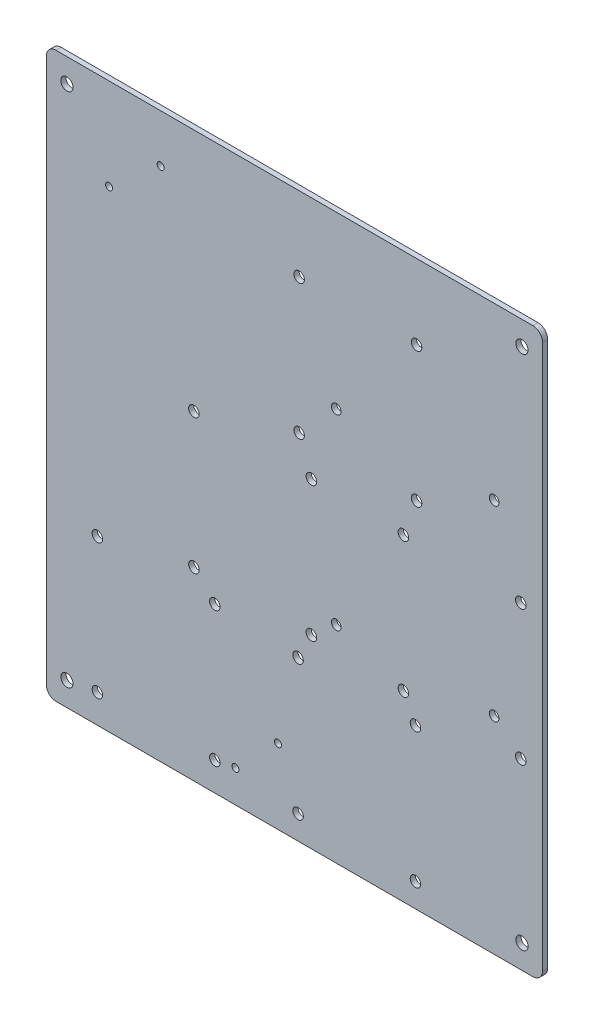
from build123d import *

# Parameters (mm, degrees)
SKETCH1_W           = 154
SKETCH1_H           = 175
BOSS_EXTRUDE1_DEPTH = 1.6
FILLET1_R           = 3
SKETCH2_R           = 1.89865
CUT_EXTRUDE1_DEPTH  = 2.6
SKETCH3_R           = 1.63195
CUT_EXTRUDE2_DEPTH  = 2.6
SKETCH4_R           = 1.5
CUT_EXTRUDE3_DEPTH  = 2.6
SKETCH5_R           = 1.09
CUT_EXTRUDE4_DEPTH  = 2.6


with BuildPart() as part:
    # Sketch1 → Boss-Extrude1 (new body)
    with BuildSketch(Plane.XY):
        Rectangle(SKETCH1_W, SKETCH1_H)
    extrude(amount=BOSS_EXTRUDE1_DEPTH)

    # Fillet1
    fillet1_edges = [part.edges().sort_by_distance(p)[0] for p in [
        (77, -87.5, 0.8),
        (-77, -87.5, 0.8),
        (-77, 87.5, 0.8),
        (77, 87.5, 0.8),
    ]]
    fillet(fillet1_edges, radius=FILLET1_R)

    # Sketch2 → Cut-Extrude1 (cut, through all)
    with BuildSketch(Plane.XY.offset(1.6)):
        with Locations((-70.612, 80.137)):
            Circle(SKETCH2_R)
        with Locations((70.612, 80.137)):
            Circle(SKETCH2_R)
        with Locations((70.612, -80.137)):
            Circle(SKETCH2_R)
        with Locations((-70.612, -80.137)):
            Circle(SKETCH2_R)
    extrude(amount=-CUT_EXTRUDE1_DEPTH, mode=Mode.SUBTRACT)

    # Sketch3 → Cut-Extrude2 (cut, through all)
    with BuildSketch(Plane.XY.offset(1.6)):
        with Locations((1.460377772, 64.310456987)):
            Circle(SKETCH3_R)
        with Locations((37.909377772, 64.310456987)):
            Circle(SKETCH3_R)
        with Locations((37.909377772, 22.400456987)):
            Circle(SKETCH3_R)
        with Locations((1.460377772, 22.400456987)):
            Circle(SKETCH3_R)
        with Locations((33.813625676, 11.150933339)):
            Circle(SKETCH3_R)
        with Locations((70.262625674, 11.150933339)):
            Circle(SKETCH3_R)
        with Locations((70.262625674, -30.759066661)):
            Circle(SKETCH3_R)
        with Locations((33.813625676, -30.759066661)):
            Circle(SKETCH3_R)
        with Locations((1.126771482, -38.187714501)):
            Circle(SKETCH3_R)
        with Locations((37.575771481, -38.187714501)):
            Circle(SKETCH3_R)
        with Locations((37.575771481, -80.097714501)):
            Circle(SKETCH3_R)
        with Locations((1.126771482, -80.097714501)):
            Circle(SKETCH3_R)
        with Locations((-31.190042853, 11.891013056)):
            Circle(SKETCH3_R)
        with Locations((5.258957145, 11.891013056)):
            Circle(SKETCH3_R)
        with Locations((5.258957145, -30.018986944)):
            Circle(SKETCH3_R)
        with Locations((-31.190042853, -30.018986944)):
            Circle(SKETCH3_R)
        with Locations((-61.163271416, -36.707555066)):
            Circle(SKETCH3_R)
        with Locations((-24.714271417, -36.707555066)):
            Circle(SKETCH3_R)
        with Locations((-24.714271417, -78.617555066)):
            Circle(SKETCH3_R)
        with Locations((-61.163271416, -78.617555066)):
            Circle(SKETCH3_R)
    extrude(amount=-CUT_EXTRUDE2_DEPTH, mode=Mode.SUBTRACT)

    # Sketch4 → Cut-Extrude3 (cut, through all)
    with BuildSketch(Plane.XY.offset(1.6)):
        with Locations((12.986023067, 34.581675178)):
            Circle(SKETCH4_R)
        with Locations((61.986023067, 34.581675178)):
            Circle(SKETCH4_R)
        with Locations((61.986023067, -23.418324822)):
            Circle(SKETCH4_R)
        with Locations((12.986023067, -23.418324822)):
            Circle(SKETCH4_R)
    extrude(amount=-CUT_EXTRUDE3_DEPTH, mode=Mode.SUBTRACT)

    # Sketch5 → Cut-Extrude4 (cut, through all)
    with BuildSketch(Plane(origin=(0, 0, 0), x_dir=(-1, 0, 0), z_dir=(0, 0, -1))):
        with Locations((41.518941969, 72.631735316)):
            Circle(SKETCH5_R)
        with Locations((57.518941969, 59.131735316)):
            Circle(SKETCH5_R)
        with Locations((18.301790213, -77.528250676)):
            Circle(SKETCH5_R)
        with Locations((5.101790213, -64.328250676)):
            Circle(SKETCH5_R)
    extrude(amount=-CUT_EXTRUDE4_DEPTH, mode=Mode.SUBTRACT)


solid = part.part
